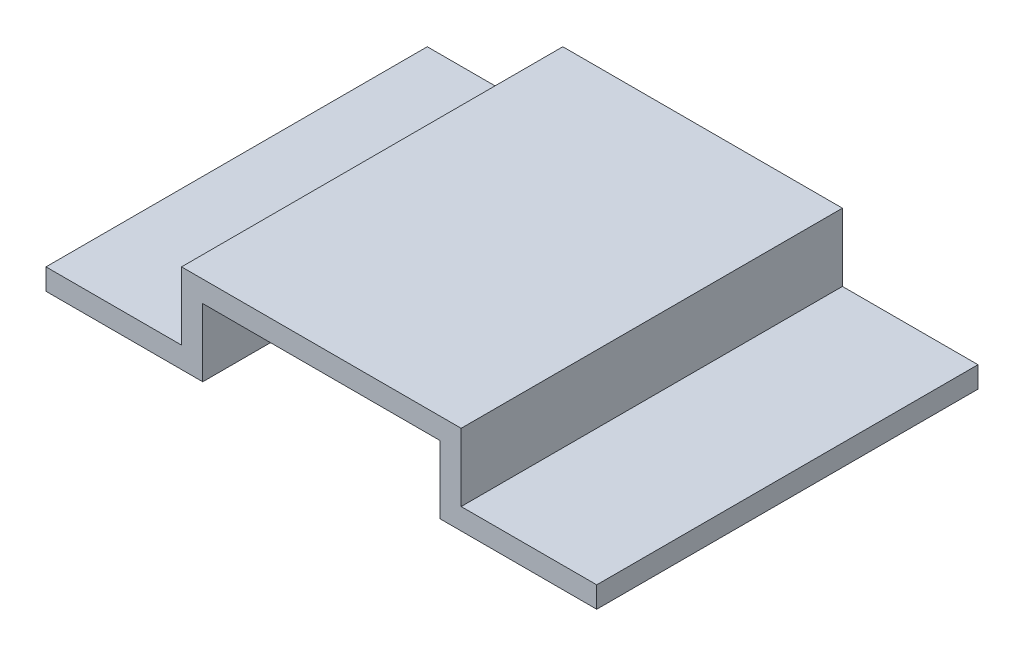
from build123d import *

# Parameters (mm, degrees)
BOSS_EXTRUDE1_DEPTH = 450


with BuildPart() as part:
    # Sketch1 → Boss-Extrude1 (new body)
    with BuildSketch(Plane.XY):
        Polygon((50, 0), (235, 0), (235, 80), (515, 80), (515, 0), (700, 0), (700, 25), (540, 25), (540, 105), (210, 105), (210, 25), (50, 25), align=None)
    extrude(amount=BOSS_EXTRUDE1_DEPTH)


solid = part.part
